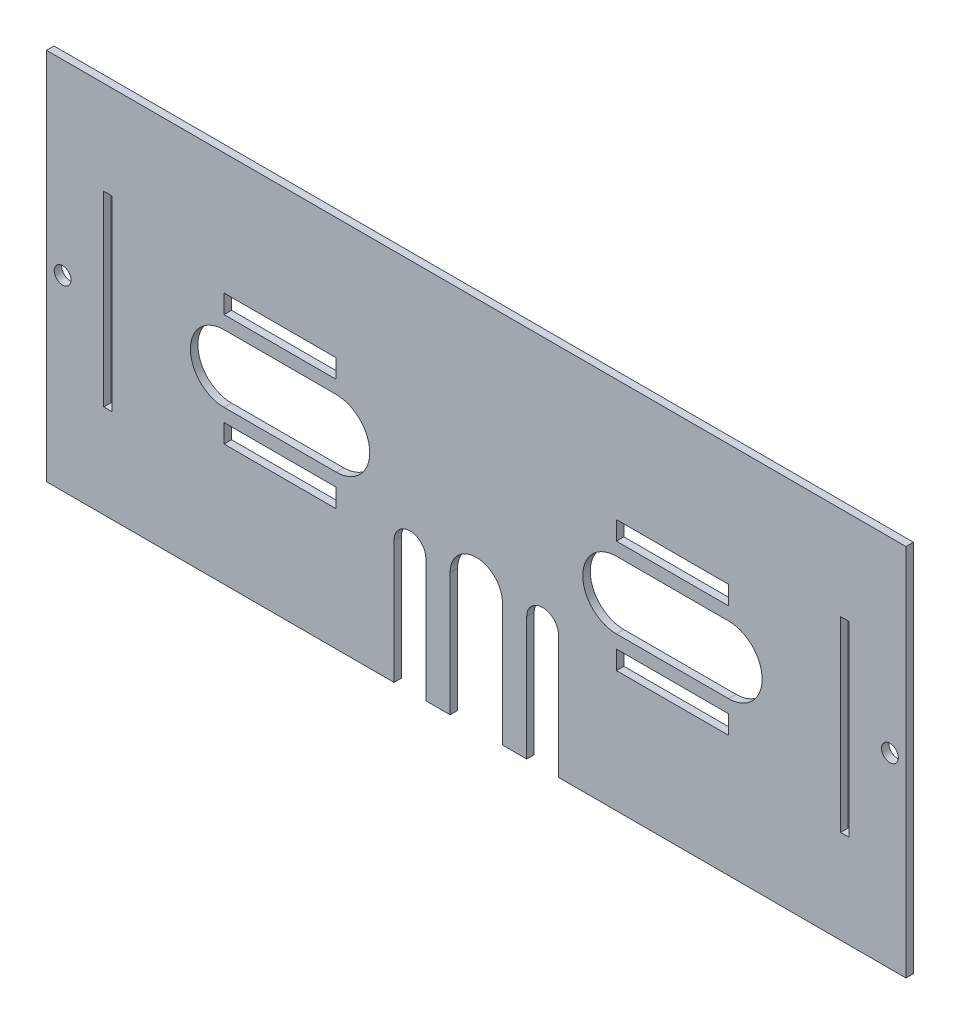
from build123d import *

# Parameters (mm, degrees)
SKETCH_1_W                    = 230
SKETCH_1_H                    = 100
EXTRUDE_1_DEPTH               = 2
CUT_EXTRUDE_2_DEPTH           = 2
CUT_EXTRUDE_2_DEPTH_BACK      = 2
SKETCH_3_W                    = 2.2
SKETCH_3_H                    = 50
SKETCH_3_W_2                  = 30
SKETCH_3_H_2                  = 5
CUT_EXTRUDE_3_DEPTH           = 2
CUT_EXTRUDE_3_DEPTH_BACK      = 2
SKETCH_5_R                    = 2.25
CUT_EXTRUDE_8_DEPTH           = 2
CUT_EXTRUDE_8_TAPER           = 1
CUT_EXTRUDE_8_OTHER_WAY_DEPTH = 2


with BuildPart() as part:
    # 草图1 → 凸台-拉伸1 (new body)
    with BuildSketch(Plane.XY):
        with Locations((65.955242642, -29.076013845)):
            Rectangle(SKETCH_1_W, SKETCH_1_H)
    extrude(amount=EXTRUDE_1_DEPTH)

    # 草图3 → 切除-拉伸2 (cut, two sides: drawn at the far end of the back side and taken through both)
    with BuildSketch(Plane.XY.offset(-CUT_EXTRUDE_2_DEPTH_BACK)):
        with Locations((-32.644757358, -29.076013845)):
            Rectangle(SKETCH_3_W, SKETCH_3_H)
        with Locations((13.455242642, -14.076013845)):
            Rectangle(SKETCH_3_W_2, SKETCH_3_H_2)
        with BuildLine():
            Line((-1.544757358, -20.076013845), (28.455242642, -20.076013845))
            ThreePointArc((28.455242642, -20.076013845), (37.455242642, -29.076013845), (28.455242642, -38.076013845))
            Line((28.455242642, -38.076013845), (-1.544757358, -38.076013845))
            ThreePointArc((-1.544757358, -38.076013845), (-10.544757358, -29.076013845), (-1.544757358, -20.076013845))
        make_face()
        with Locations((13.455242642, -44.076013845)):
            Rectangle(SKETCH_3_W_2, SKETCH_3_H_2)
        with Locations((118.455242642, -44.076013845)):
            Rectangle(SKETCH_3_W_2, SKETCH_3_H_2)
        with BuildLine():
            Line((133.455242642, -38.076013845), (103.455242642, -38.076013845))
            ThreePointArc((103.455242642, -38.076013845), (94.455242642, -29.076013845), (103.455242642, -20.076013845))
            Line((103.455242642, -20.076013845), (133.455242642, -20.076013845))
            ThreePointArc((133.455242642, -20.076013845), (142.455242642, -29.076013845), (133.455242642, -38.076013845))
        make_face()
        with Locations((118.455242642, -14.076013845)):
            Rectangle(SKETCH_3_W_2, SKETCH_3_H_2)
        with Locations((164.555242642, -29.076013845)):
            Rectangle(SKETCH_3_W, SKETCH_3_H)
    extrude(amount=CUT_EXTRUDE_2_DEPTH + CUT_EXTRUDE_2_DEPTH_BACK, mode=Mode.SUBTRACT)

    # 草图4 → 切除-拉伸3 (cut, two sides: drawn at the far end of the back side and taken through both)
    with BuildSketch(Plane.XY.offset(-CUT_EXTRUDE_3_DEPTH_BACK)):
        with BuildLine():
            Line((43.955242642, -46.076013845), (43.955242642, -79.076013845))
            Line((43.955242642, -79.076013845), (52.455242642, -79.076013845))
            Line((52.455242642, -79.076013845), (52.455242642, -46.076013845))
            ThreePointArc((52.455242642, -46.076013845), (48.205242642, -41.826013845), (43.955242642, -46.076013845))
        make_face()
        with BuildLine():
            Line((58.955242642, -46.076013845), (58.955242642, -79.076013845))
            Line((58.955242642, -79.076013845), (72.955242642, -79.076013845))
            Line((72.955242642, -79.076013845), (72.955242642, -46.076013845))
            ThreePointArc((72.955242642, -46.076013845), (65.955242642, -39.076013845), (58.955242642, -46.076013845))
        make_face()
        with BuildLine():
            Line((79.455242642, -46.076013845), (79.455242642, -79.076013845))
            Line((79.455242642, -79.076013845), (87.955242642, -79.076013845))
            Line((87.955242642, -79.076013845), (87.955242642, -46.076013845))
            ThreePointArc((87.955242642, -46.076013845), (83.705242642, -41.826013845), (79.455242642, -46.076013845))
        make_face()
    extrude(amount=CUT_EXTRUDE_3_DEPTH + CUT_EXTRUDE_3_DEPTH_BACK, mode=Mode.SUBTRACT)

    # 草图5 → 切除-拉伸8 (cut)
    with BuildSketch(Plane.XY):
        with Locations((-44.744757358, -29.076013845)):
            Circle(SKETCH_5_R)
        with Locations((176.655242642, -29.076013845)):
            Circle(SKETCH_5_R)
    extrude(amount=-CUT_EXTRUDE_8_DEPTH, taper=CUT_EXTRUDE_8_TAPER, mode=Mode.SUBTRACT)

    # 草图5 → 切除-拉伸8 other way (cut)
    with BuildSketch(Plane.XY):
        with Locations((-44.744757358, -29.076013845)):
            Circle(SKETCH_5_R)
        with Locations((176.655242642, -29.076013845)):
            Circle(SKETCH_5_R)
    extrude(amount=CUT_EXTRUDE_8_OTHER_WAY_DEPTH, mode=Mode.SUBTRACT)


solid = part.part
